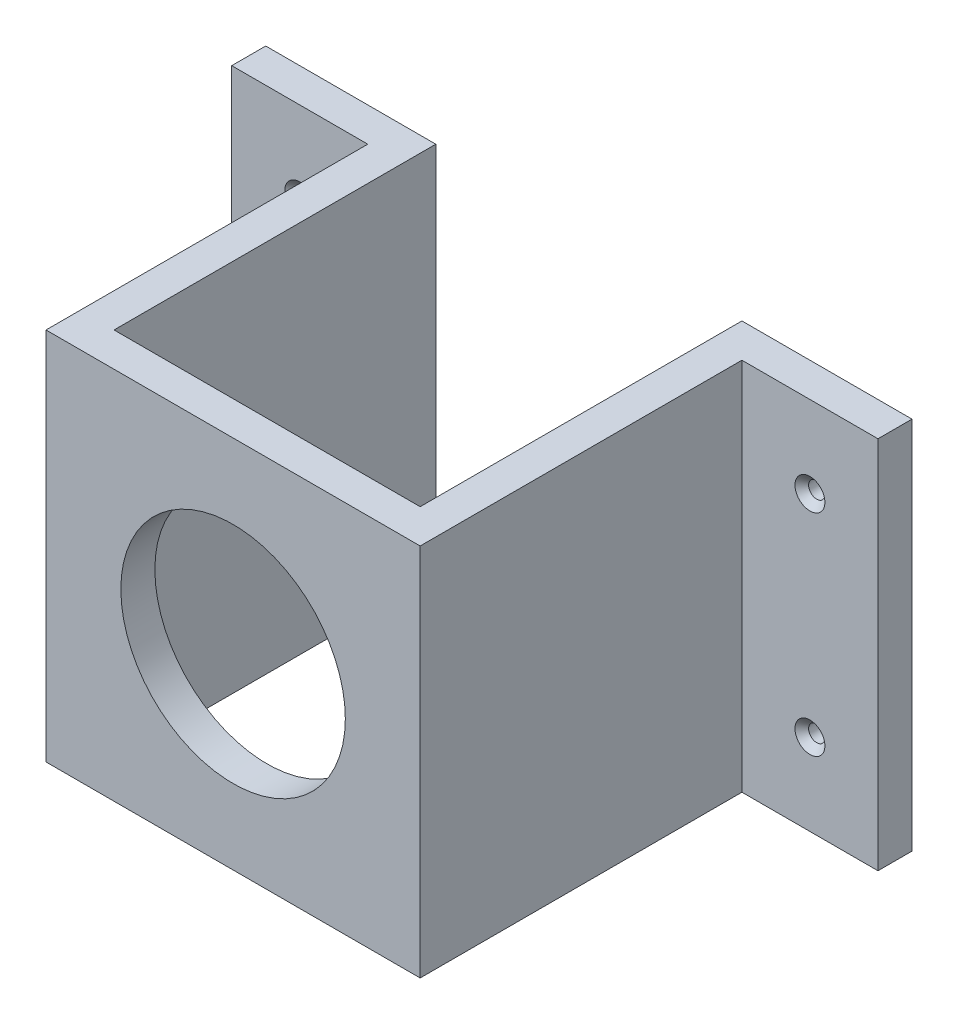
from build123d import *

# Parameters (mm, degrees)
SKETCH1_W                                       = 55
SKETCH1_H                                       = 55
BOSS_EXTRUDE1_DEPTH                             = 5
SKETCH2_W                                       = 5
SKETCH2_H                                       = 55
BOSS_EXTRUDE2_DEPTH                             = 47.3
CUT_EXTRUDE1_REACH                              = 54.3
SKETCH3_R                                       = 16.5
SKETCH4_W                                       = 5
SKETCH4_H                                       = 55
BOSS_EXTRUDE3_DEPTH                             = 20
SKETCH5_W                                       = 5
SKETCH5_H                                       = 55
BOSS_EXTRUDE4_DEPTH                             = 20
CSK_FOR_M2_FLAT_HEAD_MACHINE_SCREW1_D           = 2.4
CSK_FOR_M2_FLAT_HEAD_MACHINE_SCREW1_CSINK_D     = 4.4
CSK_FOR_M2_FLAT_HEAD_MACHINE_SCREW1_CSINK_ANGLE = 90


with BuildPart() as part:
    # Sketch1 → Boss-Extrude1 (new body)
    with BuildSketch(Plane.XY):
        Rectangle(SKETCH1_W, SKETCH1_H)
    extrude(amount=BOSS_EXTRUDE1_DEPTH)

    # Sketch2 → Boss-Extrude2 (add)
    with BuildSketch(Plane(origin=(0, 0, 0), x_dir=(-1, 0, 0), z_dir=(0, 0, -1))):
        with Locations((-25, 0)):
            Rectangle(SKETCH2_W, SKETCH2_H)
        with Locations((25, 0)):
            Rectangle(SKETCH2_W, SKETCH2_H)
    extrude(amount=BOSS_EXTRUDE2_DEPTH)

    # Sketch3 → Cut-Extrude1 (cut, up to next)
    with BuildSketch(Plane.XY.offset(5), mode=Mode.PRIVATE) as cut_extrude1_sk1:
        Circle(SKETCH3_R)
    cut_extrude1_tool1 = extrude(cut_extrude1_sk1.sketch, amount=-CUT_EXTRUDE1_REACH, mode=Mode.PRIVATE) & part.part
    add(cut_extrude1_tool1.solids().sort_by_distance((0, 0, 5))[0], mode=Mode.SUBTRACT)

    # Sketch4 → Boss-Extrude3 (add)
    with BuildSketch(Plane(origin=(27.5, 0, 0), x_dir=(0, 0, -1), z_dir=(1, 0, 0))):
        with Locations((44.8, 0)):
            Rectangle(SKETCH4_W, SKETCH4_H)
    extrude(amount=BOSS_EXTRUDE3_DEPTH)

    # Sketch5 → Boss-Extrude4 (add)
    with BuildSketch(Plane.ZY.offset(27.5)):
        with Locations((-44.8, 0)):
            Rectangle(SKETCH5_W, SKETCH5_H)
    extrude(amount=BOSS_EXTRUDE4_DEPTH)

    # CSK for M2 Flat Head Machine Screw1 (through all)
    with Locations(Plane.XY.offset(-42.3)):
        with Locations((-37.5, 15.5), (-37.5, -15.5), (37.5, 15.5), (37.5, -15.5)):
            CounterSinkHole(CSK_FOR_M2_FLAT_HEAD_MACHINE_SCREW1_D / 2, CSK_FOR_M2_FLAT_HEAD_MACHINE_SCREW1_CSINK_D / 2, counter_sink_angle=CSK_FOR_M2_FLAT_HEAD_MACHINE_SCREW1_CSINK_ANGLE)


solid = part.part
